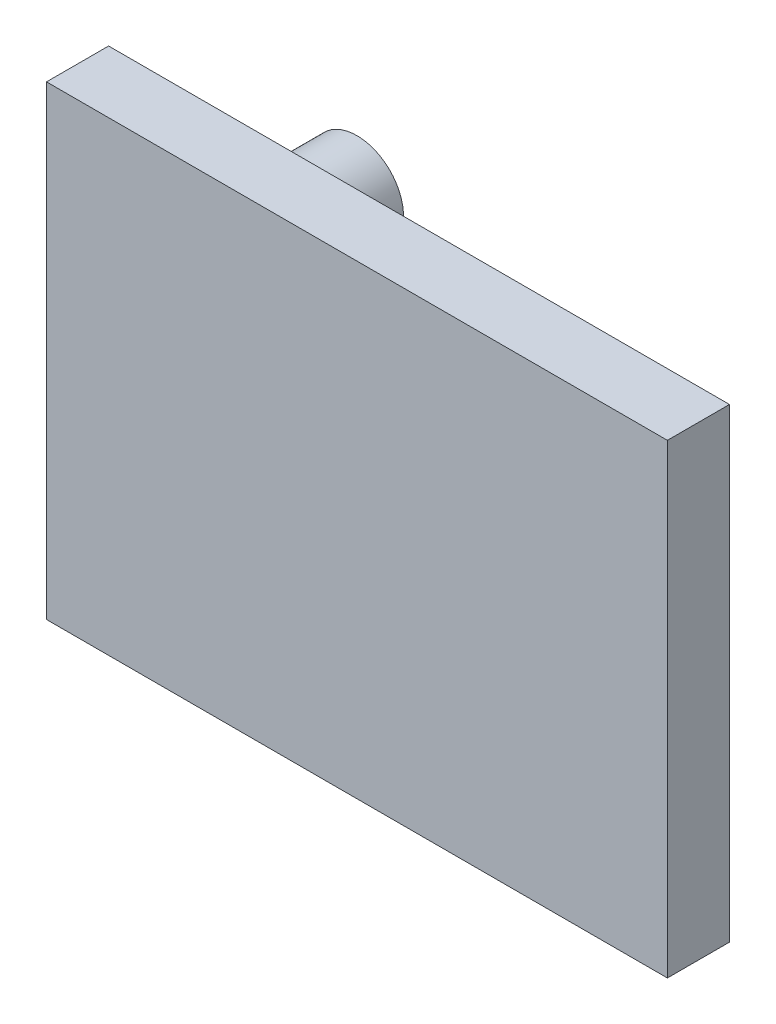
from build123d import *

# Parameters (mm, degrees)
SKETCH1_W           = 200
SKETCH1_H           = 150
BOSS_EXTRUDE1_DEPTH = 20
SKETCH2_R           = 10
SKETCH2_R_2         = 15
BOSS_EXTRUDE2_DEPTH = 30


with BuildPart() as part:
    # Sketch1 → Boss-Extrude1 (new body)
    with BuildSketch(Plane.XY):
        Rectangle(SKETCH1_W, SKETCH1_H)
    extrude(amount=BOSS_EXTRUDE1_DEPTH)

    # Sketch2 → Boss-Extrude2 (add)
    with BuildSketch(Plane(origin=(0, 0, 0), x_dir=(-1, 0, 0), z_dir=(0, 0, -1))):
        with Locations((-50, -45)):
            Circle(SKETCH2_R)
        with Locations((50, 45)):
            Circle(SKETCH2_R_2)
    extrude(amount=BOSS_EXTRUDE2_DEPTH)


solid = part.part
